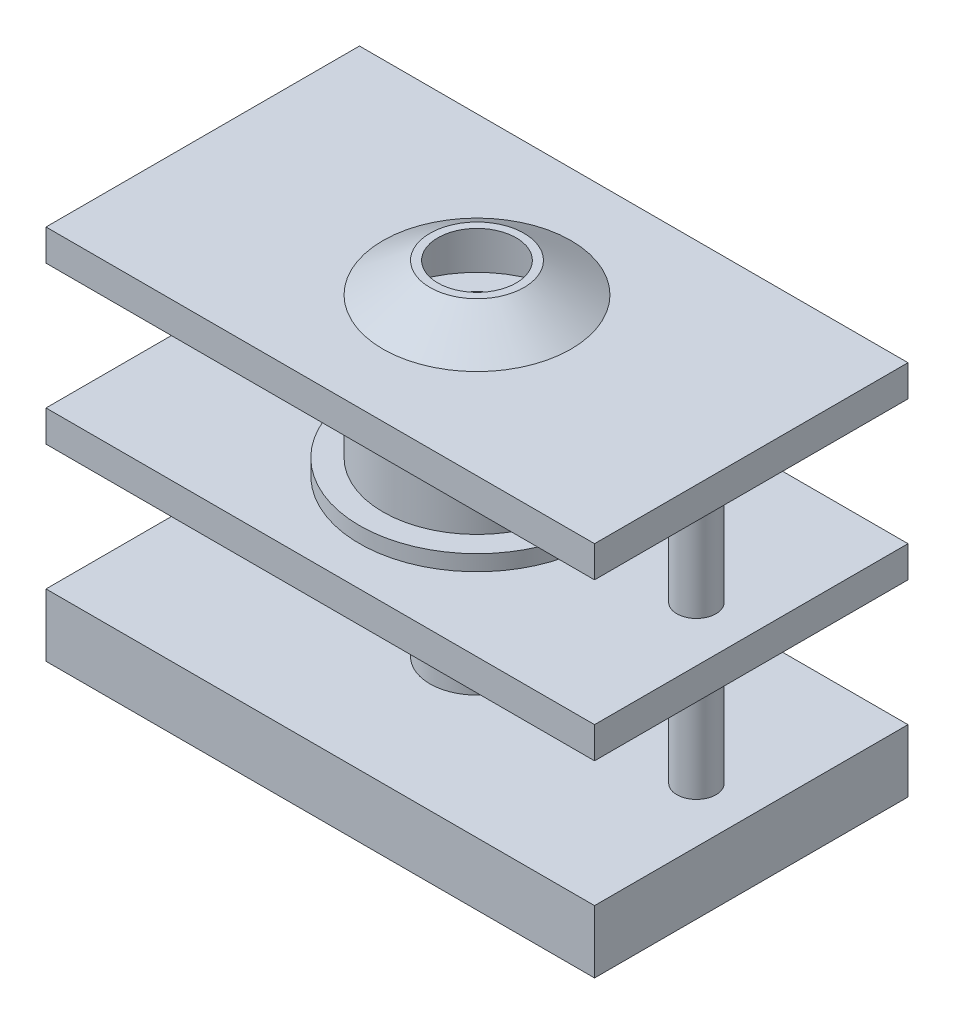
from build123d import *

# Parameters (mm, degrees)
SKETCH1_W              = 700
SKETCH1_H              = 400
SKETCH1_R              = 25
SKETCH1_R_2            = 60
BOSS_EXTRUDE1_DEPTH    = 40
SKETCH4_W              = 700
SKETCH4_H              = 400
SKETCH4_R              = 120
BOSS_EXTRUDE3_DEPTH    = 40
SKETCH5_W              = 700
SKETCH5_H              = 400
SKETCH5_R              = 25
SKETCH5_R_2            = 60
BOSS_EXTRUDE5_DEPTH    = 40
SKETCH6_R              = 60
SKETCH6_R_2            = 50
BOSS_EXTRUDE6_DEPTH    = 130
SKETCH7_R              = 25
BOSS_EXTRUDE7_DEPTH    = 160
BOSS_EXTRUDE7_2_DEPTH  = 160
SKETCH8_R              = 50
BOSS_EXTRUDE8_DEPTH    = 10
SKETCH9_R              = 5
BOSS_EXTRUDE9_DEPTH    = 140
SKETCH10_R             = 90
SKETCH10_R_2           = 60
BOSS_EXTRUDE10_DEPTH   = 30
SKETCH11_R             = 90
BOSS_EXTRUDE11_DEPTH   = 40
SKETCH12_R             = 150
SKETCH12_R_2           = 120
BOSS_EXTRUDE13_DEPTH   = 20
SKETCH13_R             = 120
SKETCH13_R_2           = 90
BOSS_EXTRUDE15_DEPTH   = 120
SKETCH17_R             = 150
SKETCH17_R_2           = 120
BOSS_EXTRUDE17_DEPTH   = 20
SKETCH18_R             = 25
BOSS_EXTRUDE18_DEPTH   = 160
BOSS_EXTRUDE18_2_DEPTH = 160


with BuildPart() as part:
    # Sketch1 → Boss-Extrude1 (new body, symmetric)
    with BuildSketch(Plane(origin=(0, 0, 0), x_dir=(1, 0, 0), z_dir=(0, 1, 0))):
        Rectangle(SKETCH1_W, SKETCH1_H)
        with Locations((-280, 0)):
            Circle(SKETCH1_R, mode=Mode.SUBTRACT)
        with Locations((280, 0)):
            Circle(SKETCH1_R, mode=Mode.SUBTRACT)
        Circle(SKETCH1_R_2, mode=Mode.SUBTRACT)
    extrude(amount=BOSS_EXTRUDE1_DEPTH, both=True)


with BuildPart() as body_2:
    # Sketch4 → Boss-Extrude3 (new body)
    with BuildSketch(Plane(origin=(0, 400, 0), x_dir=(1, 0, 0), z_dir=(0, 1, 0))):
        Rectangle(SKETCH4_W, SKETCH4_H)
        Circle(SKETCH4_R, mode=Mode.SUBTRACT)
    extrude(amount=BOSS_EXTRUDE3_DEPTH)

    # Sketch17 → Boss-Extrude17 (add)
    with BuildSketch(Plane.XZ.offset(-400)):
        Circle(SKETCH17_R)
        Circle(SKETCH17_R_2, mode=Mode.SUBTRACT)
    extrude(amount=BOSS_EXTRUDE17_DEPTH)


with BuildPart() as body_3:
    # Sketch5 → Boss-Extrude5 (new body)
    with BuildSketch(Plane(origin=(0, 200, 0), x_dir=(1, 0, 0), z_dir=(0, 1, 0))):
        Rectangle(SKETCH5_W, SKETCH5_H)
        with Locations((-280, 0)):
            Circle(SKETCH5_R, mode=Mode.SUBTRACT)
        with Locations((280, 0)):
            Circle(SKETCH5_R, mode=Mode.SUBTRACT)
        Circle(SKETCH5_R_2, mode=Mode.SUBTRACT)
    extrude(amount=BOSS_EXTRUDE5_DEPTH)

    # Sketch10 → Boss-Extrude10 (add)
    with BuildSketch(Plane(origin=(0, 170, 0), x_dir=(1, 0, 0), z_dir=(0, 1, 0))):
        with Locations((0, 1.436744995)):
            Circle(SKETCH10_R)
        Circle(SKETCH10_R_2, mode=Mode.SUBTRACT)
    extrude(amount=BOSS_EXTRUDE10_DEPTH)

    # Sketch12 → Boss-Extrude13 (add)
    with BuildSketch(Plane(origin=(0, 240, 0), x_dir=(1, 0, 0), z_dir=(0, 1, 0))):
        Circle(SKETCH12_R)
        Circle(SKETCH12_R_2, mode=Mode.SUBTRACT)
    extrude(amount=BOSS_EXTRUDE13_DEPTH)


with BuildPart() as body_4:
    # Sketch6 → Boss-Extrude6 (new body)
    with BuildSketch(Plane(origin=(0, 40, 0), x_dir=(1, 0, 0), z_dir=(0, 1, 0))):
        Circle(SKETCH6_R)
        with Locations((0, -5.12368521)):
            Circle(SKETCH6_R_2, mode=Mode.SUBTRACT)
    extrude(amount=BOSS_EXTRUDE6_DEPTH)


with BuildPart() as body_5:
    # Sketch7 → Boss-Extrude7 (new body)
    with BuildSketch(Plane(origin=(0, 40, 0), x_dir=(1, 0, 0), z_dir=(0, 1, 0))):
        with Locations((-280, 0)):
            Circle(SKETCH7_R)
    extrude(amount=BOSS_EXTRUDE7_DEPTH)


with BuildPart() as body_6:
    # Sketch7 → Boss-Extrude7 2 (new body)
    with BuildSketch(Plane(origin=(0, 40, 0), x_dir=(1, 0, 0), z_dir=(0, 1, 0))):
        with Locations((280, 0)):
            Circle(SKETCH7_R)
    extrude(amount=BOSS_EXTRUDE7_2_DEPTH)


with BuildPart() as body_7:
    # Sketch8 → Boss-Extrude8 (new body)
    with BuildSketch(Plane(origin=(0, 120, 0), x_dir=(1, 0, 0), z_dir=(0, 1, 0))):
        with Locations((0, -5.12368521)):
            Circle(SKETCH8_R)
    extrude(amount=BOSS_EXTRUDE8_DEPTH)


with BuildPart() as body_8:
    # Sketch9 → Boss-Extrude9 (new body)
    with BuildSketch(Plane(origin=(0, 130, 0), x_dir=(1, 0, 0), z_dir=(0, 1, 0))):
        Circle(SKETCH9_R)
    extrude(amount=BOSS_EXTRUDE9_DEPTH)


with BuildPart() as body_9:
    # Sketch11 → Boss-Extrude11 (new body)
    with BuildSketch(Plane(origin=(0, 270, 0), x_dir=(1, 0, 0), z_dir=(0, 1, 0))):
        Circle(SKETCH11_R)
    extrude(amount=BOSS_EXTRUDE11_DEPTH)


with BuildPart() as body_10:
    # Sketch13 → Boss-Extrude15 (new body)
    with BuildSketch(Plane(origin=(0, 260, 0), x_dir=(1, 0, 0), z_dir=(0, 1, 0))):
        Circle(SKETCH13_R)
        Circle(SKETCH13_R_2, mode=Mode.SUBTRACT)
    extrude(amount=BOSS_EXTRUDE15_DEPTH)


with BuildPart() as body_11:
    # Sketch18 → Boss-Extrude18 (new body)
    with BuildSketch(Plane(origin=(0, 240, 0), x_dir=(1, 0, 0), z_dir=(0, 1, 0))):
        with Locations((-280, 0)):
            Circle(SKETCH18_R)
    extrude(amount=BOSS_EXTRUDE18_DEPTH)


with BuildPart() as body_12:
    # Sketch18 → Boss-Extrude18 2 (new body)
    with BuildSketch(Plane(origin=(0, 240, 0), x_dir=(1, 0, 0), z_dir=(0, 1, 0))):
        with Locations((280, 0)):
            Circle(SKETCH18_R)
    extrude(amount=BOSS_EXTRUDE18_2_DEPTH)


with BuildPart() as body_13:
    # Sketch32 → Revolve1 (revolve)
    with BuildSketch(Plane.XY):
        Polygon((120, 440), (60, 478.079788953), (50, 478.079788953), (110, 440), align=None)
    revolve(axis=Axis((0, 562.46392895, 0), (0, -1, 0)))


solid = Compound([part.part, body_2.part, body_3.part, body_4.part, body_5.part, body_6.part, body_7.part, body_8.part, body_9.part, body_10.part, body_11.part, body_12.part, body_13.part])
